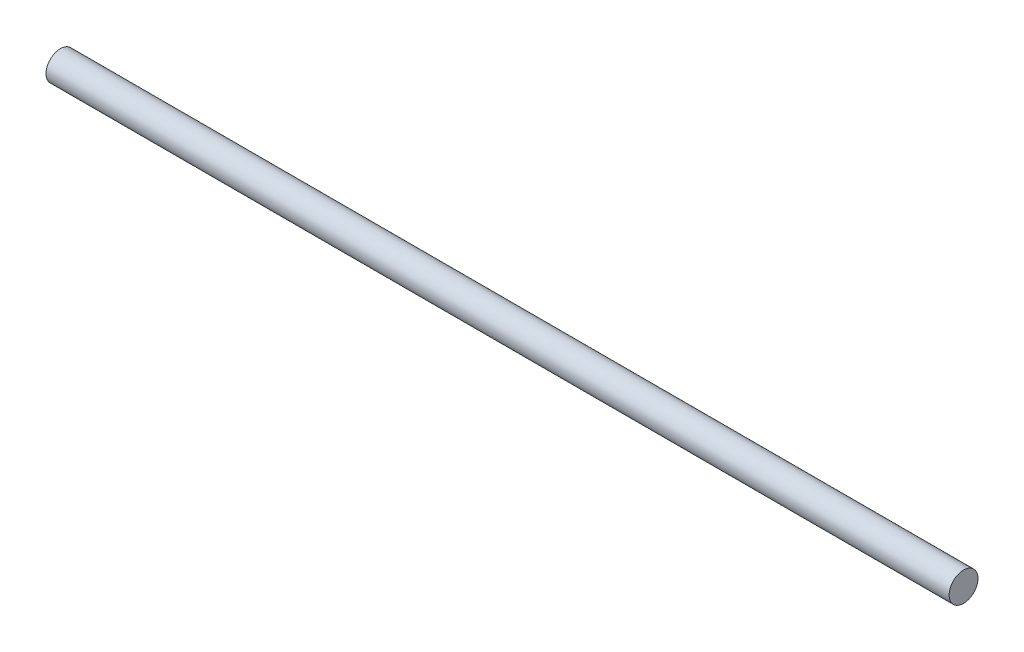
from build123d import *

# Parameters (mm, degrees)
SKETCH1_R           = 2
BOSS_EXTRUDE1_DEPTH = 62.5


with BuildPart() as part:
    # Sketch1 → Boss-Extrude1 (new body, symmetric)
    with BuildSketch(Plane(origin=(0, 0, 0), x_dir=(0, 0, -1), z_dir=(1, 0, 0))):
        Circle(SKETCH1_R)
    extrude(amount=BOSS_EXTRUDE1_DEPTH, both=True)


solid = part.part
